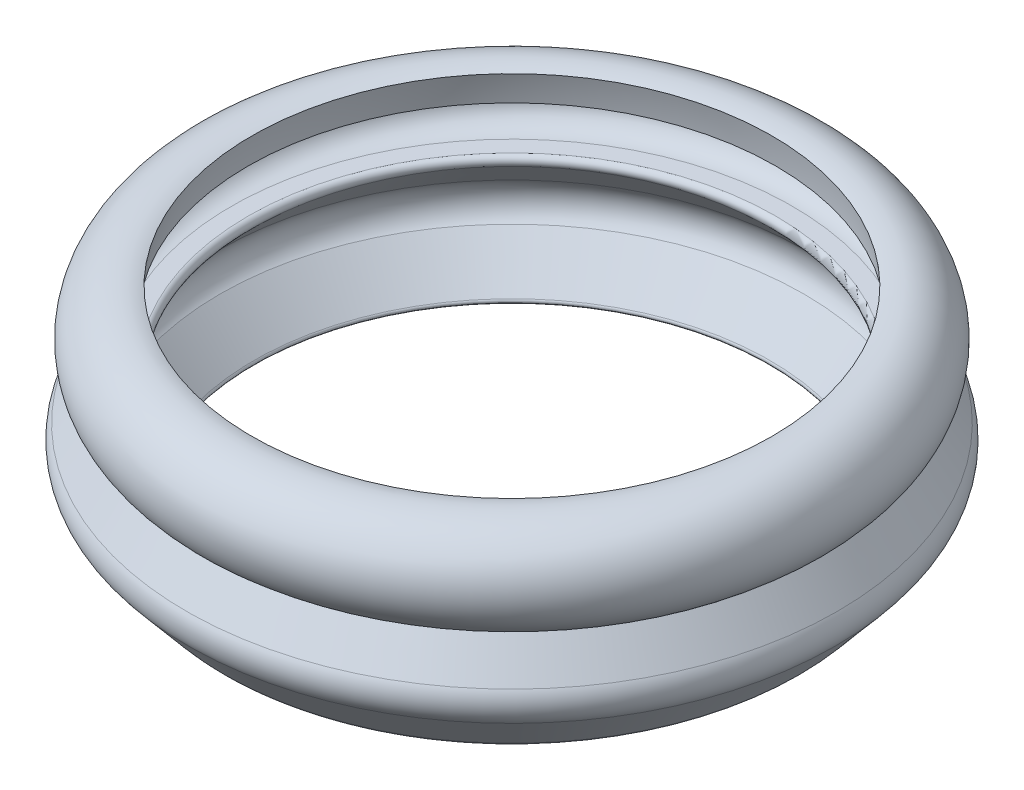
from build123d import *


with BuildPart() as part:
    # Sketch1 → Revolve1 (revolve)
    with BuildSketch(Plane.XY):
        with BuildLine():
            Line((-2.754165118, -1.954509446), (-2.438845449, -1.954509446))
            ThreePointArc((-2.438845449, -1.954509446), (-2.41196564, -1.690840976), (-2.371152225, -1.428967244))
            ThreePointArc((-2.371152225, -1.428967244), (-3.463195669, -1.876123329), (-3.195807006, -3.025475647))
            Line((-3.195807006, -3.025475647), (-3.605410268, -3.674703034))
            ThreePointArc((-3.605410268, -3.674703034), (-3.68137666, -3.97555434), (-3.565225486, -4.263289123))
            Line((-3.565225486, -4.263289123), (-2.893891556, -5.06166504))
            ThreePointArc((-2.893891556, -5.06166504), (-2.790485492, -5.140751294), (-2.663314117, -5.168588163))
            Line((-2.663314117, -5.168588163), (-2.363315669, -5.167623265))
            ThreePointArc((-2.363315669, -5.167623265), (-2.316958545, -5.135956042), (-2.329247443, -5.081176676))
            Line((-2.329247443, -5.081176676), (-2.972230128, -4.315961312))
            ThreePointArc((-2.972230128, -4.315961312), (-3.129693713, -3.96717509), (-2.99440818, -3.609202418))
            Line((-2.99440818, -3.609202418), (-2.372233059, -2.946714652))
            ThreePointArc((-2.372233059, -2.946714652), (-2.352888479, -2.84016163), (-2.436173938, -2.770942475))
            Line((-2.436173938, -2.770942475), (-2.754165118, -2.770942475))
            ThreePointArc((-2.754165118, -2.770942475), (-3.162381632, -2.36272596), (-2.754165118, -1.954509446))
        make_face()
    revolve(axis=Axis((2.543555316, -2.36272596, 0), (0, 1, 0)))


solid = part.part
